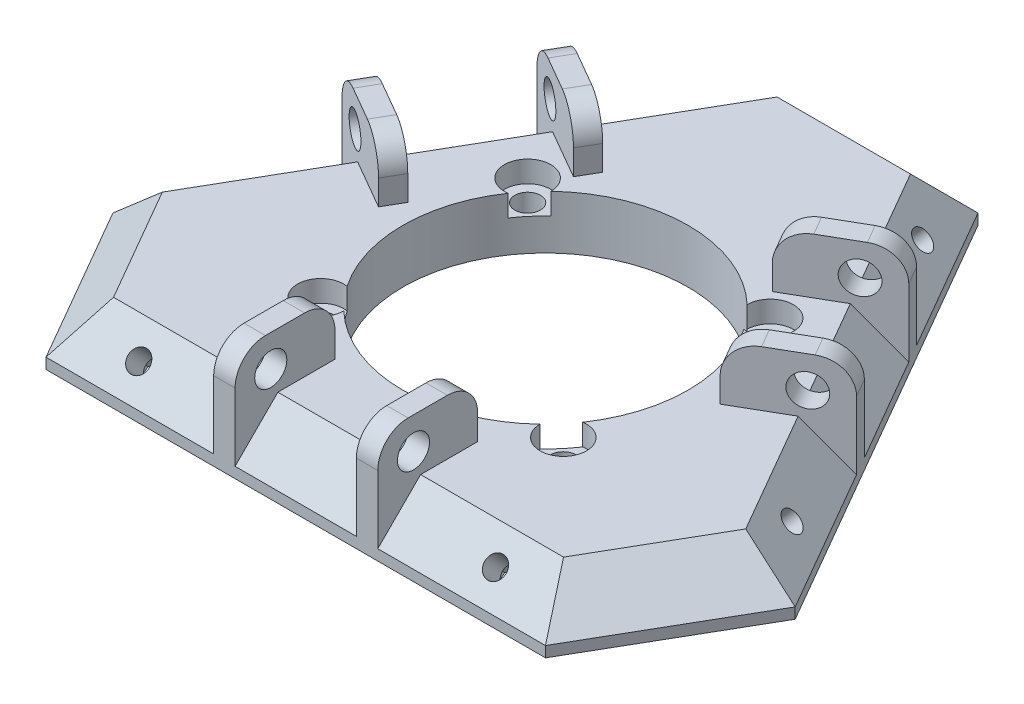
from build123d import *

# Parameters (mm, degrees)
SKETCH1_R                      = 20
BOSS_EXTRUDE1_DEPTH            = 7.5
CHAMFER2_SIZE                  = 6
CBORE_FOR_M3_SHCS1_D           = 3.6
CBORE_FOR_M3_SHCS1_CBORE_D     = 6.5
CBORE_FOR_M3_SHCS1_CBORE_DEPTH = 3
CUT_EXTRUDE1_REACH             = 61.617
SKETCH4_R                      = 1.5
CUT_EXTRUDE2_START             = -3.5
CUT_EXTRUDE2_DEPTH             = 10
SKETCH7_R                      = 1.5
CUT_EXTRUDE3_DEPTH             = 10
CUT_EXTRUDE4_START             = -3.5
CUT_EXTRUDE4_DEPTH             = 10
SKETCH9_R                      = 1.5
CUT_EXTRUDE5_DEPTH             = 10
CUT_EXTRUDE6_START             = -3.5
CUT_EXTRUDE6_DEPTH             = 10
SKETCH11_W                     = 3
SKETCH11_H                     = 14
BOSS_EXTRUDE2_DEPTH            = 15.25
CUT_EXTRUDE7_START             = -60.310889132
SKETCH12_R                     = 2.25
CUT_EXTRUDE7_DEPTH             = 97.621778265
FILLET1_R                      = 4.25
FILLET1_OF_MIRROR4_R           = 4.25
FILLET1_OF_MIRROR5_R           = 4.25


with BuildPart() as part:
    # Sketch1 → Boss-Extrude1 (new body)
    with BuildSketch(Plane(origin=(0, 42.804564232, 0), x_dir=(1, 0, 0), z_dir=(0, 1, 0))):
        Polygon((72.89779828, -65.265836883), (37.89779828, -4.644058618), (12.276020015, -4.644058618), (-22.723979985, -65.265836883), (-9.913090852, -87.454947751), (60.086909148, -87.454947751), align=None)
        with Locations((25.086909148, -52.454947751)):
            Circle(SKETCH1_R, mode=Mode.SUBTRACT)
    extrude(amount=BOSS_EXTRUDE1_DEPTH)

    # Chamfer2
    chamfer2_edges = [part.edges().sort_by_distance(p)[0] for p in [
        (-16.318535418, 50.304564232, 76.360392317),
        (25.086909148, 50.304564232, 87.454947751),
        (66.492353714, 50.304564232, 76.360392317),
        (55.39779828, 50.304564232, 34.954947751),
        (25.086909148, 50.304564232, 4.644058618),
        (-5.223979985, 50.304564232, 34.954947751),
    ]]
    chamfer(chamfer2_edges, length=CHAMFER2_SIZE)

    # CBORE for M3 SHCS1 (through all)
    with Locations(Plane(origin=(0, 50.304564232, 0), x_dir=(1, 0, 0), z_dir=(0, 1, 0))):
        with Locations((8.086909148, -37.954947751), (42.086909148, -37.954947751), (42.086909148, -66.954947751), (8.086909148, -66.954947751)):
            CounterBoreHole(CBORE_FOR_M3_SHCS1_D / 2, CBORE_FOR_M3_SHCS1_CBORE_D / 2, CBORE_FOR_M3_SHCS1_CBORE_DEPTH)

    # Sketch4 → Cut-Extrude1 (cut, up to next)
    with BuildSketch(Plane(origin=(0, 65.879755991, 65.879755991), x_dir=(1, 0, 0), z_dir=(0, 0.707106781, 0.707106781)), mode=Mode.PRIVATE) as cut_extrude1_sk1:
        with Locations((0.086909148, -26.26928811)):
            Circle(SKETCH4_R)
    cut_extrude1_tool1 = extrude(cut_extrude1_sk1.sketch, amount=-CUT_EXTRUDE1_REACH, mode=Mode.PRIVATE) & part.part
    add(cut_extrude1_tool1.solids().sort_by_distance((0.086909, 47.304564, 84.454948))[0], mode=Mode.SUBTRACT)
    # Sketch4 → Cut-Extrude1 (cut, up to next)
    with BuildSketch(Plane(origin=(0, 65.879755991, 65.879755991), x_dir=(1, 0, 0), z_dir=(0, 0.707106781, 0.707106781)), mode=Mode.PRIVATE) as cut_extrude1_sk2:
        with Locations((50.086909148, -26.26928811)):
            Circle(SKETCH4_R)
    cut_extrude1_tool2 = extrude(cut_extrude1_sk2.sketch, amount=-CUT_EXTRUDE1_REACH, mode=Mode.PRIVATE) & part.part
    add(cut_extrude1_tool2.solids().sort_by_distance((50.086909, 47.304564, 84.454948))[0], mode=Mode.SUBTRACT)

    # Sketch5 → Cut-Extrude2 (cut)
    with BuildSketch(Plane(origin=(0, 65.879755991, 65.879755991), x_dir=(1, 0, 0), z_dir=(0, 0.707106781, 0.707106781)).offset(CUT_EXTRUDE2_START)):
        Polygon((3.262335628, -26.26928811), (1.674622388, -23.51928811), (-1.500804092, -23.51928811), (-3.088517333, -26.26928811), (-1.500804092, -29.01928811), (1.674622388, -29.01928811), align=None)
        Polygon((48.499195908, -29.01928811), (46.911482667, -26.26928811), (48.499195908, -23.51928811), (51.674622388, -23.51928811), (53.262335628, -26.26928811), (51.674622388, -29.01928811), align=None)
    extrude(amount=-CUT_EXTRUDE2_DEPTH, mode=Mode.SUBTRACT)

    # Sketch7 → Cut-Extrude3 (cut)
    with BuildSketch(Plane(origin=(-13.575463373, 15.675594866, -7.837797433), x_dir=(0.790569415, 0.547722558, -0.273861279), z_dir=(-0.612372436, 0.707106781, -0.353553391))):
        with Locations((29.661607386, -34.396624037)):
            Circle(SKETCH7_R)
        with Locations((-1.961169216, -73.126457499)):
            Circle(SKETCH7_R)
    extrude(amount=-CUT_EXTRUDE3_DEPTH, mode=Mode.SUBTRACT)

    # Sketch8 → Cut-Extrude4 (cut)
    with BuildSketch(Plane(origin=(-13.575463373, 15.675594866, -7.837797433), x_dir=(0.790569415, 0.547722558, -0.273861279), z_dir=(-0.612372436, 0.707106781, -0.353553391)).offset(CUT_EXTRUDE4_START)):
        Polygon((32.795906248, -34.906039363), (31.66992343, -31.936949262), (28.535624567, -31.427533937), (26.527308523, -33.887208712), (27.653291342, -36.856298813), (30.787590204, -37.365714138), align=None)
        Polygon((1.173129647, -73.635872825), (-0.835186398, -76.0955476), (-3.96948526, -75.586132275), (-5.095468078, -72.617042174), (-3.087152034, -70.157367399), (0.047146828, -70.666782724), align=None)
    extrude(amount=-CUT_EXTRUDE4_DEPTH, mode=Mode.SUBTRACT)

    # Sketch9 → Cut-Extrude5 (cut)
    with BuildSketch(Plane(origin=(32.390645234, 37.401495491, -18.700747745), x_dir=(0.790569415, -0.547722558, 0.273861279), z_dir=(0.612372436, 0.707106781, -0.353553391))):
        with Locations((41.627055396, -73.126457499)):
            Circle(SKETCH9_R)
        with Locations((10.004278795, -34.396624037)):
            Circle(SKETCH9_R)
    extrude(amount=-CUT_EXTRUDE5_DEPTH, mode=Mode.SUBTRACT)

    # Sketch10 → Cut-Extrude6 (cut)
    with BuildSketch(Plane(origin=(32.390645234, 37.401495491, -18.700747745), x_dir=(0.790569415, -0.547722558, 0.273861279), z_dir=(0.612372436, 0.707106781, -0.353553391)).offset(CUT_EXTRUDE6_START)):
        Polygon((39.618739352, -70.666782724), (38.492756534, -73.635872825), (40.501072578, -76.0955476), (43.63537144, -75.586132275), (44.761354259, -72.617042174), (42.753038215, -70.157367399), align=None)
        Polygon((13.138577657, -33.887208712), (12.012594839, -36.856298813), (8.878295976, -37.365714138), (6.869979932, -34.906039363), (7.99596275, -31.936949262), (11.130261613, -31.427533937), align=None)
    extrude(amount=-CUT_EXTRUDE6_DEPTH, mode=Mode.SUBTRACT)

    # Sketch11 → Boss-Extrude2 (add)
    with BuildSketch(Plane(origin=(0, 42.804564232, 0), x_dir=(1, 0, 0), z_dir=(0, 1, 0))):
        with Locations((35.086909148, -80.454947751)):
            Rectangle(SKETCH11_W, SKETCH11_H)
        with Locations((15.086909148, -80.454947751)):
            Rectangle(SKETCH11_W, SKETCH11_H)
    boss_extrude2 = extrude(amount=BOSS_EXTRUDE2_DEPTH)

    # Sketch12 → Cut-Extrude7 (cut)
    with BuildSketch(Plane(origin=(36.586909148, 0, 0), x_dir=(0, 0, -1), z_dir=(1, 0, 0)).offset(CUT_EXTRUDE7_START)):
        with Locations((-82.454947751, 53.621218058)):
            Circle(SKETCH12_R)
    cut_extrude7 = extrude(amount=CUT_EXTRUDE7_DEPTH, mode=Mode.SUBTRACT)

    # Fillet1
    fillet1_edges = [part.edges().sort_by_distance(p)[0] for p in [
        (35.086909148, 58.054564232, 87.454947751),
        (35.086909148, 58.054564232, 73.454947751),
        (15.086909148, 58.054564232, 87.454947751),
        (15.086909148, 58.054564232, 73.454947751),
    ]]
    fillet(fillet1_edges, radius=FILLET1_R)

    # Mirror4: Boss-Extrude2, Cut-Extrude7 across plane
    add(boss_extrude2.mirror(Plane(origin=(28.98538594, 0, 50.204161125), x_dir=(-0.866025404, 0, 0.5), z_dir=(0.5, 0, 0.866025404))))
    add(cut_extrude7.mirror(Plane(origin=(28.98538594, 0, 50.204161125), x_dir=(-0.866025404, 0, 0.5), z_dir=(0.5, 0, 0.866025404))), mode=Mode.SUBTRACT)

    # Fillet1 of Mirror4
    fillet1_of_mirror4_edges = [part.edges().sort_by_distance(p)[0] for p in [
        (-0.223979985, 58.054564232, 26.294693713),
        (11.900375668, 58.054564232, 33.294693713),
        (-10.223979985, 58.054564232, 43.615201789),
        (1.900375668, 58.054564232, 50.615201789),
    ]]
    fillet(fillet1_of_mirror4_edges, radius=FILLET1_OF_MIRROR4_R)

    # Mirror5: Boss-Extrude2, Cut-Extrude7 across plane
    add(boss_extrude2.mirror(Plane(origin=(-16.441931366, 0, 28.478260501), x_dir=(0.866025404, 0, 0.5), z_dir=(-0.5, 0, 0.866025404))))
    add(cut_extrude7.mirror(Plane(origin=(-16.441931366, 0, 28.478260501), x_dir=(0.866025404, 0, 0.5), z_dir=(-0.5, 0, 0.866025404))), mode=Mode.SUBTRACT)

    # Fillet1 of Mirror5
    fillet1_of_mirror5_edges = [part.edges().sort_by_distance(p)[0] for p in [
        (60.39779828, 58.054564232, 43.615201789),
        (48.273442627, 58.054564232, 50.615201789),
        (50.39779828, 58.054564232, 26.294693713),
        (38.273442627, 58.054564232, 33.294693713),
    ]]
    fillet(fillet1_of_mirror5_edges, radius=FILLET1_OF_MIRROR5_R)


solid = part.part
